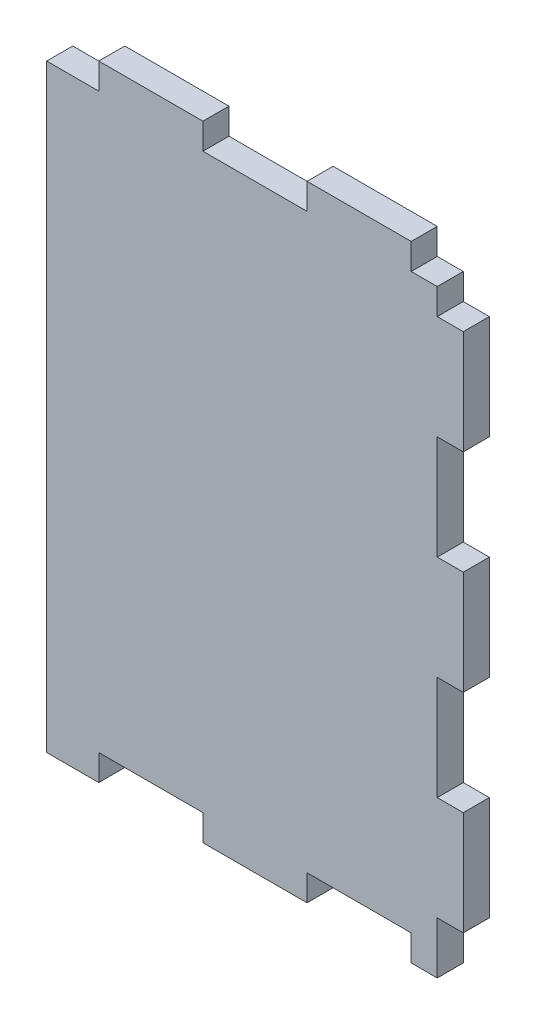
from build123d import *

# Parameters (mm, degrees)
SKETCH1_W          = 50.8
SKETCH1_H          = 76.2
EXTRUDE1_DEPTH     = 3.175
SKETCH3_W          = 3.175
SKETCH3_H          = 6.35
CUT_EXTRUDE1_DEPTH = 3.175
LPATTERN1_COUNT    = 2
LPATTERN1_PITCH    = 69.85
SKETCH4_W          = 3.175
SKETCH4_H          = 12.7
CUT_EXTRUDE2_DEPTH = 3.175
LPATTERN2_COUNT    = 5
LPATTERN2_PITCH    = 25.4
SKETCH5_W          = 12.7
SKETCH5_H          = 3.175
CUT_EXTRUDE3_DEPTH = 3.175
SKETCH6_W          = 6.35
SKETCH6_H          = 3.175
CUT_EXTRUDE4_DEPTH = 3.175
LPATTERN3_COUNT    = 2
LPATTERN3_PITCH    = 44.45
LPATTERN4_COUNT    = 2
LPATTERN4_PITCH    = 25.4
SKETCH7_W          = 12.7
SKETCH7_H          = 3.175
CUT_EXTRUDE5_DEPTH = 4.175


with BuildPart() as part:
    # Sketch1 → Extrude1 (new body)
    with BuildSketch(Plane.XY):
        with Locations((25.4, 38.1)):
            Rectangle(SKETCH1_W, SKETCH1_H)
    extrude(amount=EXTRUDE1_DEPTH)

    # Sketch3 → Cut-Extrude1 (cut)
    with BuildSketch(Plane.XY.offset(3.175)):
        with Locations((49.2125, 73.025)):
            Rectangle(SKETCH3_W, SKETCH3_H)
    cut_extrude1 = extrude(amount=-CUT_EXTRUDE1_DEPTH, mode=Mode.SUBTRACT)

    # LPattern1: Cut-Extrude1 ×2
    with Locations(*[(0, -i * LPATTERN1_PITCH, 0) for i in range(1, LPATTERN1_COUNT)]):
        add(cut_extrude1, mode=Mode.SUBTRACT)

    # Sketch4 → Cut-Extrude2 (cut)
    with BuildSketch(Plane.XY.offset(3.175)):
        with Locations((49.2125, 50.8)):
            Rectangle(SKETCH4_W, SKETCH4_H)
    cut_extrude2 = extrude(amount=-CUT_EXTRUDE2_DEPTH, mode=Mode.SUBTRACT)

    # LPattern2: Cut-Extrude2 ×5
    with Locations(*[(0, -i * LPATTERN2_PITCH, 0) for i in range(1, LPATTERN2_COUNT)]):
        add(cut_extrude2, mode=Mode.SUBTRACT)

    # Sketch5 → Cut-Extrude3 (cut)
    with BuildSketch(Plane.XY.offset(3.175)):
        with Locations((12.7, 1.5875)):
            Rectangle(SKETCH5_W, SKETCH5_H)
    cut_extrude3 = extrude(amount=-CUT_EXTRUDE3_DEPTH, mode=Mode.SUBTRACT)

    # Sketch6 → Cut-Extrude4 (cut)
    with BuildSketch(Plane.XY.offset(3.175)):
        with Locations((3.175, 74.6125)):
            Rectangle(SKETCH6_W, SKETCH6_H)
    cut_extrude4 = extrude(amount=-CUT_EXTRUDE4_DEPTH, mode=Mode.SUBTRACT)

    # LPattern3: Cut-Extrude4 ×2
    with Locations(*[(i * LPATTERN3_PITCH, 0, 0) for i in range(1, LPATTERN3_COUNT)]):
        add(cut_extrude4, mode=Mode.SUBTRACT)

    # LPattern4: Cut-Extrude3 ×2
    with Locations(*[(i * LPATTERN4_PITCH, 0, 0) for i in range(1, LPATTERN4_COUNT)]):
        add(cut_extrude3, mode=Mode.SUBTRACT)

    # Sketch7 → Cut-Extrude5 (cut, through all)
    with BuildSketch(Plane.XY.offset(3.175)):
        with Locations((25.4, 74.6125)):
            Rectangle(SKETCH7_W, SKETCH7_H)
    extrude(amount=-CUT_EXTRUDE5_DEPTH, mode=Mode.SUBTRACT)


solid = part.part
